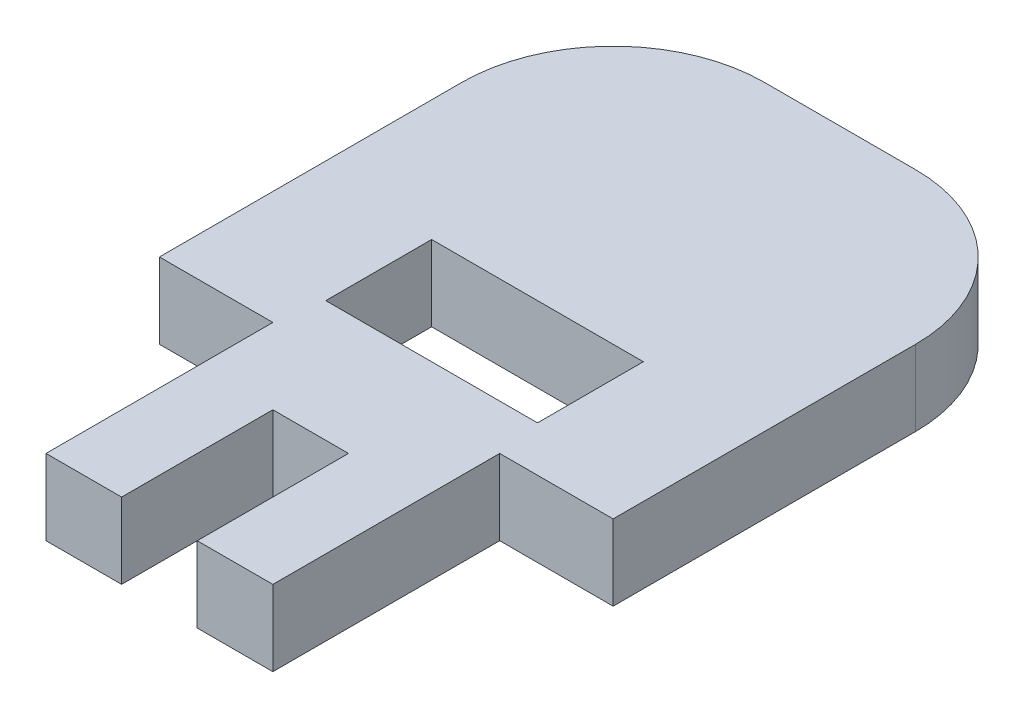
from build123d import *

# Parameters (mm, degrees)
BOSS_EXTRUDE1_DEPTH = 6.35
SKETCH2_W           = 17.78
SKETCH2_H           = 8.89
CUT_EXTRUDE1_DEPTH  = 6.35
SKETCH3_W           = 6.35
SKETCH3_H           = 6.35
BOSS_EXTRUDE2_DEPTH = 12.7


with BuildPart() as part:
    # Sketch1 → Boss-Extrude1 (new body)
    with BuildSketch(Plane(origin=(0, 0, 0), x_dir=(1, 0, 0), z_dir=(0, 1, 0))):
        with BuildLine():
            Line((9.525, -3.175), (-9.525, -3.175))
            Line((-9.525, -3.175), (-9.525, 3.175))
            Line((-9.525, 3.175), (-19.05, 3.175))
            Line((-19.05, 3.175), (-19.05, 28.575))
            ThreePointArc((-19.05, 28.575), (-15.330256121, 37.555256121), (-6.35, 41.275))
            Line((-6.35, 41.275), (6.35, 41.275))
            ThreePointArc((6.35, 41.275), (15.330256121, 37.555256121), (19.05, 28.575))
            Line((19.05, 28.575), (19.05, 3.175))
            Line((19.05, 3.175), (9.525, 3.175))
            Line((9.525, 3.175), (9.525, -3.175))
        make_face()
    extrude(amount=BOSS_EXTRUDE1_DEPTH)

    # Sketch2 → Cut-Extrude1 (cut)
    with BuildSketch(Plane(origin=(0, 6.35, 0), x_dir=(1, 0, 0), z_dir=(0, 1, 0))):
        with Locations((0, 11.43)):
            Rectangle(SKETCH2_W, SKETCH2_H)
    extrude(amount=-CUT_EXTRUDE1_DEPTH, mode=Mode.SUBTRACT)

    # Sketch3 → Boss-Extrude2 (add)
    with BuildSketch(Plane.XY.offset(3.175)):
        with Locations((-6.35, 3.175)):
            Rectangle(SKETCH3_W, SKETCH3_H)
        with Locations((6.35, 3.175)):
            Rectangle(SKETCH3_W, SKETCH3_H)
    extrude(amount=BOSS_EXTRUDE2_DEPTH)


solid = part.part
